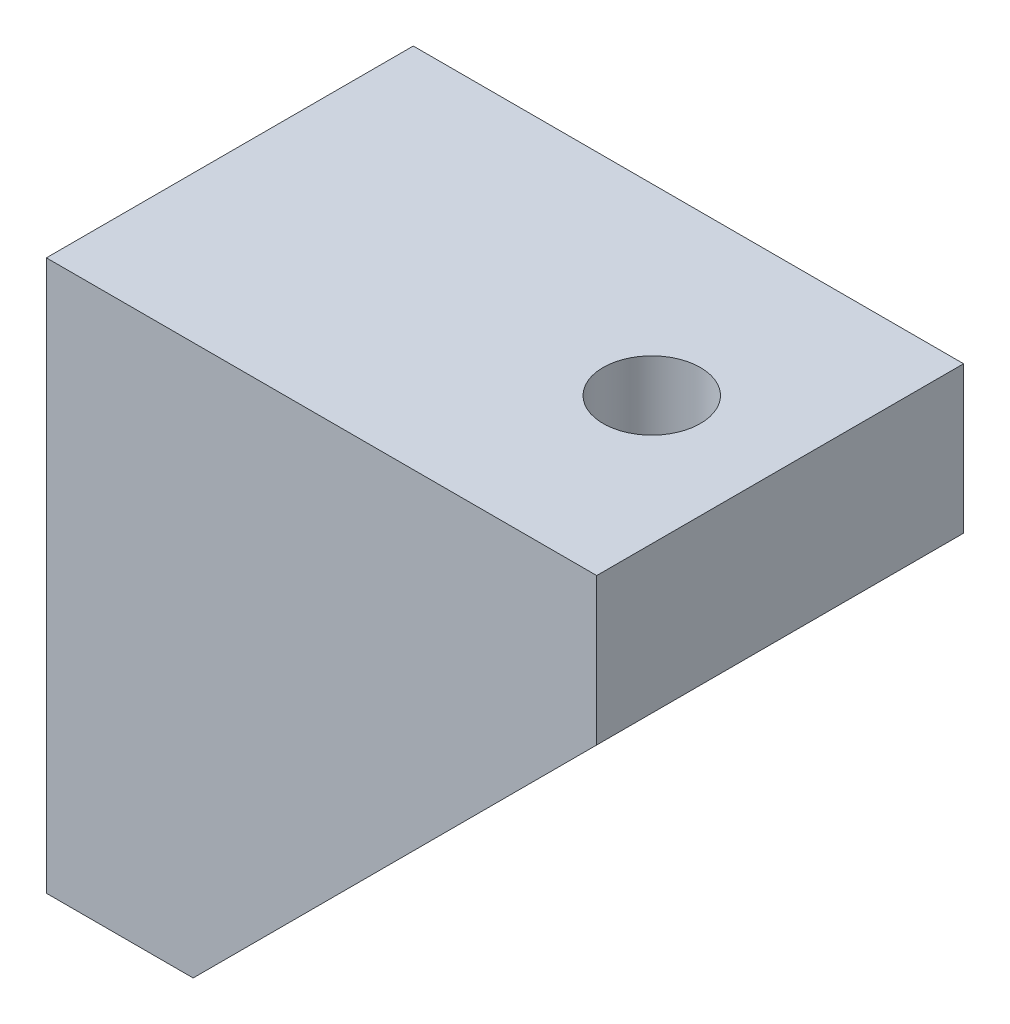
from build123d import *

# Parameters (mm, degrees)
BOSS_EXTRUDE1_DEPTH = 4
BOSS_EXTRUDE2_DEPTH = 12
BOSS_EXTRUDE3_DEPTH = 4
SKETCH4_R           = 2.65
CUT_EXTRUDE1_DEPTH  = 8
SKETCH5_R           = 2.65
CUT_EXTRUDE2_DEPTH  = 8


with BuildPart() as part:
    # Sketch1 → Boss-Extrude1 (new body)
    with BuildSketch(Plane.XY):
        Polygon((0, 0), (0, 30), (30, 30), (30, 22), (8, 0), align=None)
    extrude(amount=BOSS_EXTRUDE1_DEPTH)

    # Sketch2 → Boss-Extrude2 (add)
    with BuildSketch(Plane.XY.offset(4)):
        Polygon((0, 0), (8, 0), (8, 22), (30, 22), (30, 30), (0, 30), align=None)
    extrude(amount=BOSS_EXTRUDE2_DEPTH)

    # Sketch3 → Boss-Extrude3 (add)
    with BuildSketch(Plane.XY.offset(16)):
        Polygon((0, 30), (0, 0), (8, 0), (30, 22), (30, 30), align=None)
    extrude(amount=BOSS_EXTRUDE3_DEPTH)

    # Sketch4 → Cut-Extrude1 (cut)
    with BuildSketch(Plane(origin=(8, 0, 0), x_dir=(0, 0, -1), z_dir=(1, 0, 0))):
        with Locations((-10, 11)):
            Circle(SKETCH4_R)
    extrude(amount=-CUT_EXTRUDE1_DEPTH, mode=Mode.SUBTRACT)

    # Sketch5 → Cut-Extrude2 (cut)
    with BuildSketch(Plane.XZ.offset(-22)):
        with Locations((23, 10)):
            Circle(SKETCH5_R)
    extrude(amount=-CUT_EXTRUDE2_DEPTH, mode=Mode.SUBTRACT)


solid = part.part
